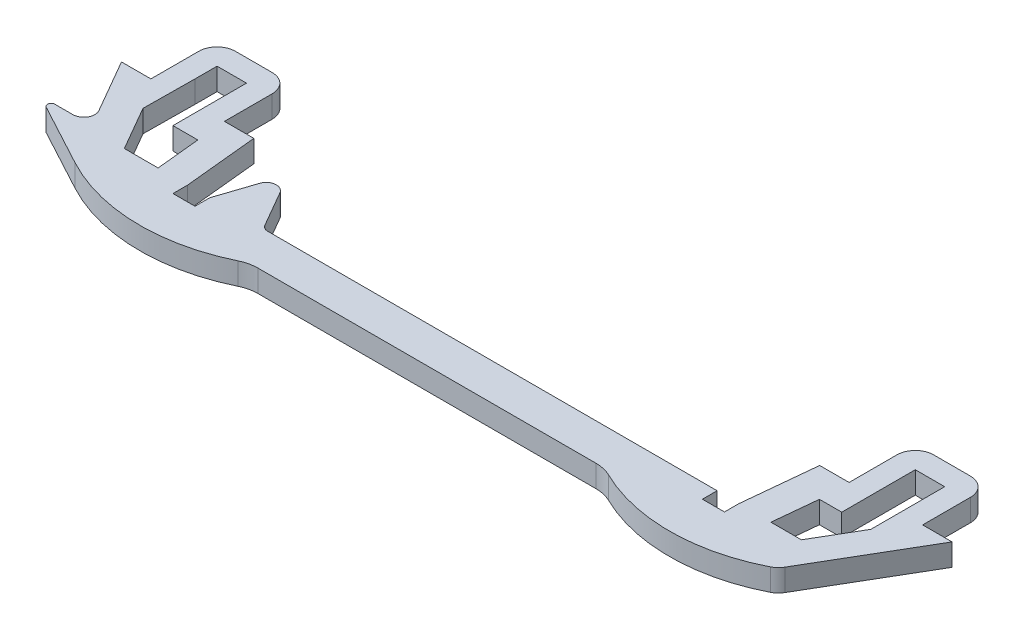
from build123d import *

# Parameters (mm, degrees)
BOSS_EXTRUDE1_DEPTH = 3
FILLET2_R           = 2.5
FILLET3_R           = 1
FILLET5_R           = 2.5
FILLET6_R           = 5


with BuildPart() as part:
    # Sketch1 → Boss-Extrude1 (new body)
    with BuildSketch(Plane(origin=(0, 0, 0), x_dir=(1, 0, 0), z_dir=(0, 1, 0))):
        with BuildLine():
            Line((-62.418566214, -47.137504987), (-58.418566214, -47.137504987))
            Line((-58.418566214, -47.137504987), (-58.418566214, -38.137504987))
            Line((-58.418566214, -38.137504987), (-48.418566214, -38.137504987))
            Line((-48.418566214, -38.137504987), (-48.418566214, -47.137504987))
            Line((-48.418566214, -47.137504987), (-44.418566214, -47.137504987))
            Line((-44.418566214, -47.137504987), (-43.418817081, -57.134996312))
            Line((-43.418817081, -57.134996312), (-43.418817081, -59.137504987))
            Line((-43.418817081, -59.137504987), (-40.418817081, -59.137504987))
            Line((-40.418817081, -59.137504987), (-40.418817081, -57.137504987))
            Line((-40.418817081, -57.137504987), (-38.722684913, -52.023499684))
            ThreePointArc((-38.722684913, -52.023499684), (-37.561438496, -51.091888176), (-36.235977812, -51.769787298))
            Line((-36.235977812, -51.769787298), (-33.13692456, -57.137504987))
            Line((-33.13692456, -57.137504987), (28.581433786, -57.137504987))
            Line((28.581433786, -57.137504987), (28.581433786, -59.137504987))
            Line((28.581433786, -59.137504987), (31.581433786, -59.137504987))
            Line((31.581433786, -59.137504987), (31.581433786, -57.187643384))
            Line((31.581433786, -57.187643384), (32.581433786, -47.190177149))
            Line((32.581433786, -47.190177149), (36.581433786, -47.190177149))
            Line((36.581433786, -47.190177149), (36.581433786, -38.190177149))
            Line((36.581433786, -38.190177149), (46.581433786, -38.190177149))
            Line((46.581433786, -38.190177149), (46.581433786, -47.190177149))
            Line((46.581433786, -47.190177149), (50.581433786, -47.190177149))
            Line((50.581433786, -47.190177149), (41.830582941, -62.137504987))
            ThreePointArc((41.830582941, -62.137504987), (30.081433786, -65.137504987), (18.332284631, -62.137504987))
            Line((18.332284631, -62.137504987), (-30.079321987, -62.137504987))
            ThreePointArc((-30.079321987, -62.137504987), (-41.918817081, -65.137504987), (-53.758312176, -62.137504987))
            Line((-53.758312176, -62.137504987), (-62.202371167, -57.589552191))
            ThreePointArc((-62.202371167, -57.589552191), (-62.450096964, -57.027082233), (-61.965274707, -56.649341709))
            Line((-61.965274707, -56.649341709), (-59.524980934, -56.649341709))
            ThreePointArc((-59.524980934, -56.649341709), (-58.225942828, -55.899341709), (-58.225942828, -54.399341709))
            Line((-58.225942828, -54.399341709), (-62.418566214, -47.137504987))
        make_face()
        Polygon((36.547763078, -51.190177149), (39.581433786, -51.190177149), (39.581433786, -44.190177149), (39.581433786, -41.190177149), (43.581433786, -41.190177149), (43.581433786, -44.22970007), (43.581433786, -51.22970007), (40.093380681, -57.187643384), (35.947864455, -57.187643384), align=None, mode=Mode.SUBTRACT)
        Polygon((-55.418566214, -41.137504987), (-51.418566214, -41.137504987), (-51.418566214, -44.137504987), (-51.418566214, -51.137504987), (-48.038516462, -51.137504987), (-47.438516462, -57.137504987), (-52.026261368, -57.137504987), (-55.490362984, -51.137504987), (-55.418566214, -44.137873195), align=None, mode=Mode.SUBTRACT)
    extrude(amount=BOSS_EXTRUDE1_DEPTH)

    # Fillet2
    fillet2_edges = [part.edges().sort_by_distance(p)[0] for p in [
        (-58.418566214, 1.5, 38.137504987),
        (-48.418566214, 1.5, 38.137504987),
        (36.581433786, 1.5, 38.190177149),
        (46.581433786, 1.5, 38.190177149),
    ]]
    fillet(fillet2_edges, radius=FILLET2_R)

    # Fillet3
    fillet3_edges = [part.edges().sort_by_distance(p)[0] for p in [
        (-33.13692456, 1.5, 57.137504987),
    ]]
    fillet(fillet3_edges, radius=FILLET3_R)

    # Fillet5
    fillet5_edges = [part.edges().sort_by_distance(p)[0] for p in [
        (41.830582941, 1.5, 62.137504987),
        (-53.758312176, 1.5, 62.137504987),
    ]]
    fillet(fillet5_edges, radius=FILLET5_R)

    # Fillet6
    fillet6_edges = [part.edges().sort_by_distance(p)[0] for p in [
        (18.332284631, 1.5, 62.137504987),
        (-30.079321987, 1.5, 62.137504987),
    ]]
    fillet(fillet6_edges, radius=FILLET6_R)


solid = part.part
